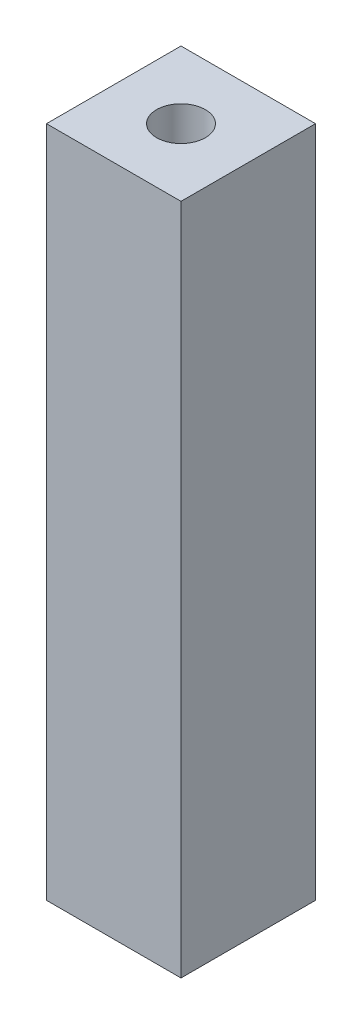
from build123d import *

# Parameters (mm, degrees)
SKETCH1_W           = 8
SKETCH1_H           = 8
BOSS_EXTRUDE1_DEPTH = 40
SKETCH2_R           = 1.45
CUT_EXTRUDE1_DEPTH  = 41


with BuildPart() as part:
    # Sketch1 → Boss-Extrude1 (new body)
    with BuildSketch(Plane(origin=(0, 0, 0), x_dir=(1, 0, 0), z_dir=(0, 1, 0))):
        Rectangle(SKETCH1_W, SKETCH1_H)
    extrude(amount=BOSS_EXTRUDE1_DEPTH)

    # Sketch2 → Cut-Extrude1 (cut, through all)
    with BuildSketch(Plane(origin=(0, 40, 0), x_dir=(1, 0, 0), z_dir=(0, 1, 0))):
        Circle(SKETCH2_R)
    extrude(amount=-CUT_EXTRUDE1_DEPTH, mode=Mode.SUBTRACT)


solid = part.part
